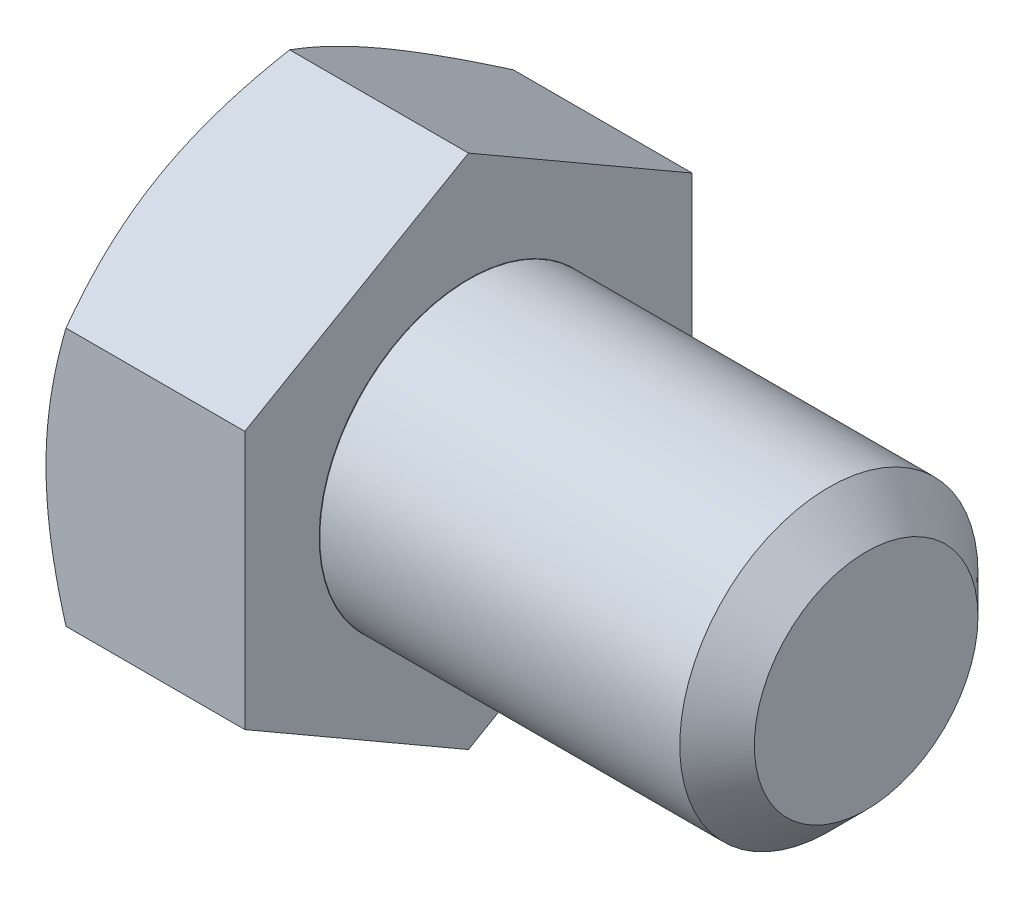
from build123d import *

# Parameters (mm, degrees)
SKETCH5_R           = 4.7625
BOSS_EXTRUDE3_DEPTH = 12.7
CHAMFER1_SIZE       = 1.190625
BOSS_EXTRUDE4_DEPTH = 6.35
SKETCH8_OUTSIDE_W   = 91.538
SKETCH8_OUTSIDE_H   = 93.748
SKETCH8_OUTSIDE_R   = 7.14375
CUT_EXTRUDE3_DEPTH  = 20.05
CUT_EXTRUDE3_TAPER  = 60


with BuildPart() as part:
    # Sketch5 → Boss-Extrude3 (new body)
    with BuildSketch(Plane(origin=(9.525, 0, 0), x_dir=(0, 0, -1), z_dir=(1, 0, 0))):
        Circle(SKETCH5_R)
    extrude(amount=-BOSS_EXTRUDE3_DEPTH)

    # Chamfer1
    chamfer1_edges = [part.edges().sort_by_distance(p)[0] for p in [
        (9.525, 0, 4.7625),
    ]]
    chamfer(chamfer1_edges, length=CHAMFER1_SIZE)



with BuildPart() as body_2:
    # Sketch6 → Boss-Extrude4 (new body)
    with BuildSketch(Plane.ZY.offset(3.175)):
        Polygon((7.14375, 4.124445986), (0, 8.248891971), (-7.14375, 4.124445986), (-7.14375, -4.124445986), (0, -8.248891971), (7.14375, -4.124445986), align=None)
    extrude(amount=BOSS_EXTRUDE4_DEPTH)

    # Sketch8 outside → Cut-Extrude3 (cut, through all)
    with BuildSketch(Plane.ZY.offset(9.525)):
        Rectangle(SKETCH8_OUTSIDE_W, SKETCH8_OUTSIDE_H)
        Circle(SKETCH8_OUTSIDE_R, mode=Mode.SUBTRACT)
    extrude(amount=-CUT_EXTRUDE3_DEPTH, taper=CUT_EXTRUDE3_TAPER, mode=Mode.SUBTRACT)


with BuildPart() as part_1:
    add(part.part)

    add(body_2.part)  # Revolve7 merges body 2
    # Sketch13 → Revolve7 (revolve)
    with BuildSketch(Plane.XY):
        Polygon((-3.429, 0), (5.084670523, 0), (-3.175, 4.768723), (-3.429, 4.768723), align=None)
    revolve(axis=Axis((-3.429, 0, 0), (1, 0, 0)))


solid = part_1.part
